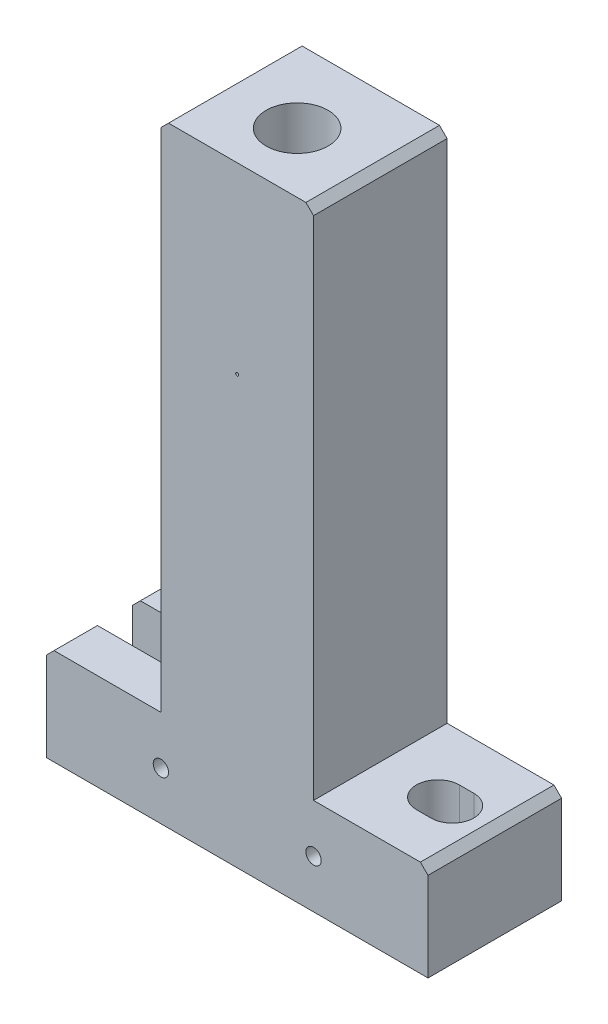
from build123d import *

# Parameters (mm, degrees)
EXTRUDE1_DEPTH                        = 44.45
CHAMFER1_SIZE                         = 2.54
CHAMFER2_SIZE                         = 2.54
F_13_16_0_8125_DIAMETER_HOLE1_D       = 20.6375
F_13_16_0_8125_DIAMETER_HOLE1_DEPTH   = 63.754
F_1_2_20_TAPPED_HOLE1_D               = 11.50874
F_1_2_20_TAPPED_HOLE1_DEPTH           = 82.55
F_1_2_20_TAPPED_HOLE1_TIP             = 3.322287069
F_60_0_04_DIAMETER_HOLE1_REACH        = 46.45
F_60_0_04_DIAMETER_HOLE1_BORE_R       = 0.508
F_1_4_20_TAPPED_HOLE1_D               = 5.1054
F_1_4_0_25_DIAMETER_HOLE2_D           = 6.36778
F_1_4_0_25_DIAMETER_HOLE2_DEPTH       = 12.7
F_1_4_0_25_DIAMETER_HOLE2_CSINK_D     = 9.652
F_1_4_0_25_DIAMETER_HOLE2_CSINK_ANGLE = 90
F_1_4_0_25_DIAMETER_HOLE2_TIP         = 1.913074116
EXTRUDE4_DEPTH                        = 12.7
CHAMFER3_SIZE                         = 1.524
EXTRUDE5_DEPTH                        = 33.131


with BuildPart() as part:
    # Sketch1 → Extrude1 (new body)
    with BuildSketch(Plane.XY):
        Polygon((-63.5, 19.16234013), (-25.4, 19.16234013), (-25.4, 190.23134013), (0, 190.23134013), (0, -12.96865987), (-63.5, -12.96865987), align=None)
    extrude1 = extrude(amount=EXTRUDE1_DEPTH)

    # Mirror2: Extrude1 across plane
    add(extrude1.mirror(Plane(origin=(0, -12.96865987, 44.45), x_dir=(0, 0, 1), z_dir=(-1, 0, 0))))

    # Chamfer1
    chamfer1_edges = [part.edges().sort_by_distance(p)[0] for p in [
        (63.5, 19.16234013, 22.225),
        (25.4, 190.23134013, 22.225),
    ]]
    chamfer(chamfer1_edges, length=CHAMFER1_SIZE)

    # Chamfer2
    chamfer2_edges = [part.edges().sort_by_distance(p)[0] for p in [
        (-63.5, 19.16234013, 22.225),
        (-25.4, 190.23134013, 22.225),
    ]]
    chamfer(chamfer2_edges, length=CHAMFER2_SIZE)

    # 13/16 (0.8125) Diameter Hole1
    with Locations(Plane(origin=(0, 190.23134013, 24.511), x_dir=(0, 0, 1), z_dir=(0, 1, 0))):
        with Locations((0, 0)):
            Hole(F_13_16_0_8125_DIAMETER_HOLE1_D / 2, depth=F_13_16_0_8125_DIAMETER_HOLE1_DEPTH)

    # 1/2-20 Tapped Hole1
    with Locations(Plane(origin=(0, 126.47734013, 24.511), x_dir=(0, 0, 1), z_dir=(0, 1, 0))):
        with Locations((0, 0)):
            Hole(F_1_2_20_TAPPED_HOLE1_D / 2, depth=F_1_2_20_TAPPED_HOLE1_DEPTH)
            with Locations((0, 0, -(F_1_2_20_TAPPED_HOLE1_DEPTH + F_1_2_20_TAPPED_HOLE1_TIP / 2))):  # 120° drill point
                Cone(0, F_1_2_20_TAPPED_HOLE1_D / 2, F_1_2_20_TAPPED_HOLE1_TIP, mode=Mode.SUBTRACT)

    # #60 (0.04) Diameter Hole1 bore → #60 (0.04) Diameter Hole1 (cut, up to next)
    with BuildSketch(Plane.XY.offset(44.45), mode=Mode.PRIVATE) as f_60_0_04_diameter_hole1_sk1:
        with Locations((0, 129.27134013)):
            Circle(F_60_0_04_DIAMETER_HOLE1_BORE_R)
    f_60_0_04_diameter_hole1_tool1 = extrude(f_60_0_04_diameter_hole1_sk1.sketch, amount=-F_60_0_04_DIAMETER_HOLE1_REACH, mode=Mode.PRIVATE) & part.part
    add(f_60_0_04_diameter_hole1_tool1.solids().sort_by_distance((0, 129.27134, 44.45))[0], mode=Mode.SUBTRACT)

    # 1/4-20 Tapped Hole1 (through all)
    with Locations(Plane(origin=(0, 0, 0), x_dir=(-1, 0, 0), z_dir=(0, 0, -1))):
        with Locations((-25.4, 3.09684013), (25.4, 3.09684013)):
            Hole(F_1_4_20_TAPPED_HOLE1_D / 2)

    # 1/4 (0.25) Diameter Hole2
    with Locations(Plane(origin=(0, 0, 0), x_dir=(-1, 0, 0), z_dir=(0, 0, -1))):
        with Locations((-9.525, 3.09684013)):
            CounterSinkHole(F_1_4_0_25_DIAMETER_HOLE2_D / 2, F_1_4_0_25_DIAMETER_HOLE2_CSINK_D / 2, depth=F_1_4_0_25_DIAMETER_HOLE2_DEPTH, counter_sink_angle=F_1_4_0_25_DIAMETER_HOLE2_CSINK_ANGLE)
            with Locations((0, 0, -(F_1_4_0_25_DIAMETER_HOLE2_DEPTH + F_1_4_0_25_DIAMETER_HOLE2_TIP / 2))):  # 118° drill point
                Cone(0, F_1_4_0_25_DIAMETER_HOLE2_D / 2, F_1_4_0_25_DIAMETER_HOLE2_TIP, mode=Mode.SUBTRACT)

    # Sketch23 → Extrude4 (cut)
    with BuildSketch(Plane(origin=(0, 0, 0), x_dir=(-1, 0, 0), z_dir=(0, 0, -1))):
        with BuildLine():
            Line((6.35, 6.28073013), (12.7, 6.28073013))
            ThreePointArc((12.7, 6.28073013), (15.88389, 3.09684013), (12.7, -0.08704987))
            Line((12.7, -0.08704987), (6.35, -0.08704987))
            ThreePointArc((6.35, -0.08704987), (3.16611, 3.09684013), (6.35, 6.28073013))
        make_face()
    extrude(amount=-EXTRUDE4_DEPTH, mode=Mode.SUBTRACT)

    # Chamfer3
    chamfer3_edges = [part.edges().sort_by_distance(p)[0] for p in [
        (-3.16611, 3.09684013, 0),
        (-9.525, -0.08704987, 0),
        (-15.88389, 3.09684013, 0),
        (-9.525, 6.28073013, 0),
    ]]
    chamfer(chamfer3_edges, length=CHAMFER3_SIZE)

    # Sketch24 → Extrude5 (cut, through all)
    with BuildSketch(Plane(origin=(0, 19.16234013, 0), x_dir=(1, 0, 0), z_dir=(0, 1, 0))):
        with BuildLine():
            Line((45.183374064, -15.7226), (50.009374064, -15.7226))
            ThreePointArc((50.009374064, -15.7226), (57.146774064, -22.86), (50.009374064, -29.9974))
            Line((50.009374064, -29.9974), (45.183374064, -29.9974))
            ThreePointArc((45.183374064, -29.9974), (38.045974064, -22.86), (45.183374064, -15.7226))
        make_face()
        with BuildLine():
            Line((-38.255625936, -29.9974), (-63.655625936, -29.9974))
            ThreePointArc((-63.655625936, -29.9974), (-70.793025936, -22.86), (-63.655625936, -15.7226))
            Line((-63.655625936, -15.7226), (-38.255625936, -15.7226))
            ThreePointArc((-38.255625936, -15.7226), (-31.118225936, -22.86), (-38.255625936, -29.9974))
        make_face()
    extrude(amount=-EXTRUDE5_DEPTH, mode=Mode.SUBTRACT)


solid = part.part
